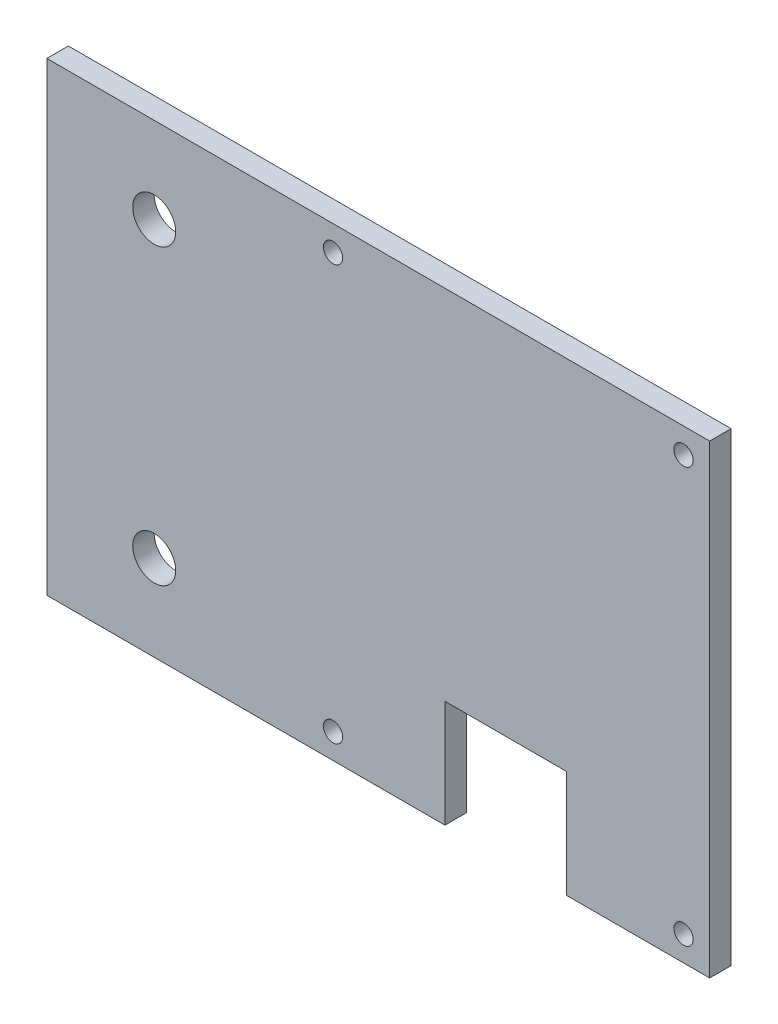
from build123d import *

# Parameters (mm, degrees)
SKETCH1_W           = 92.65
SKETCH1_H           = 65
SKETCH1_R           = 3
SKETCH1_R_2         = 1.35
BOSS_EXTRUDE1_DEPTH = 3
SKETCH2_R           = 1.35
CUT_EXTRUDE1_DEPTH  = 4
SKETCH3_W           = 17
SKETCH3_H           = 15
CUT_EXTRUDE2_DEPTH  = 4
SKETCH4_R           = 3
CUT_EXTRUDE3_DEPTH  = 4


with BuildPart() as part:
    # Sketch1 → Boss-Extrude1 (new body)
    with BuildSketch(Plane.XY):
        with Locations((46.325, 32.5)):
            Rectangle(SKETCH1_W, SKETCH1_H)
        with Locations((15, 53)):
            Circle(SKETCH1_R, mode=Mode.SUBTRACT)
        with Locations((40, 61.5)):
            Circle(SKETCH1_R_2, mode=Mode.SUBTRACT)
        with Locations((40, 3.5)):
            Circle(SKETCH1_R_2, mode=Mode.SUBTRACT)
    extrude(amount=BOSS_EXTRUDE1_DEPTH)

    # Sketch2 → Cut-Extrude1 (cut, through all)
    with BuildSketch(Plane.XY.offset(3)):
        with Locations((89, 61.5)):
            Circle(SKETCH2_R)
        with Locations((89, 3.5)):
            Circle(SKETCH2_R)
    extrude(amount=-CUT_EXTRUDE1_DEPTH, mode=Mode.SUBTRACT)

    # Sketch3 → Cut-Extrude2 (cut, through all)
    with BuildSketch(Plane.XY.offset(3)):
        with Locations((64.15, 7.5)):
            Rectangle(SKETCH3_W, SKETCH3_H)
    extrude(amount=-CUT_EXTRUDE2_DEPTH, mode=Mode.SUBTRACT)

    # Sketch4 → Cut-Extrude3 (cut, through all)
    with BuildSketch(Plane(origin=(0, 0, 0), x_dir=(-1, 0, 0), z_dir=(0, 0, -1))):
        with Locations((-15, 12)):
            Circle(SKETCH4_R)
    extrude(amount=-CUT_EXTRUDE3_DEPTH, mode=Mode.SUBTRACT)


solid = part.part
